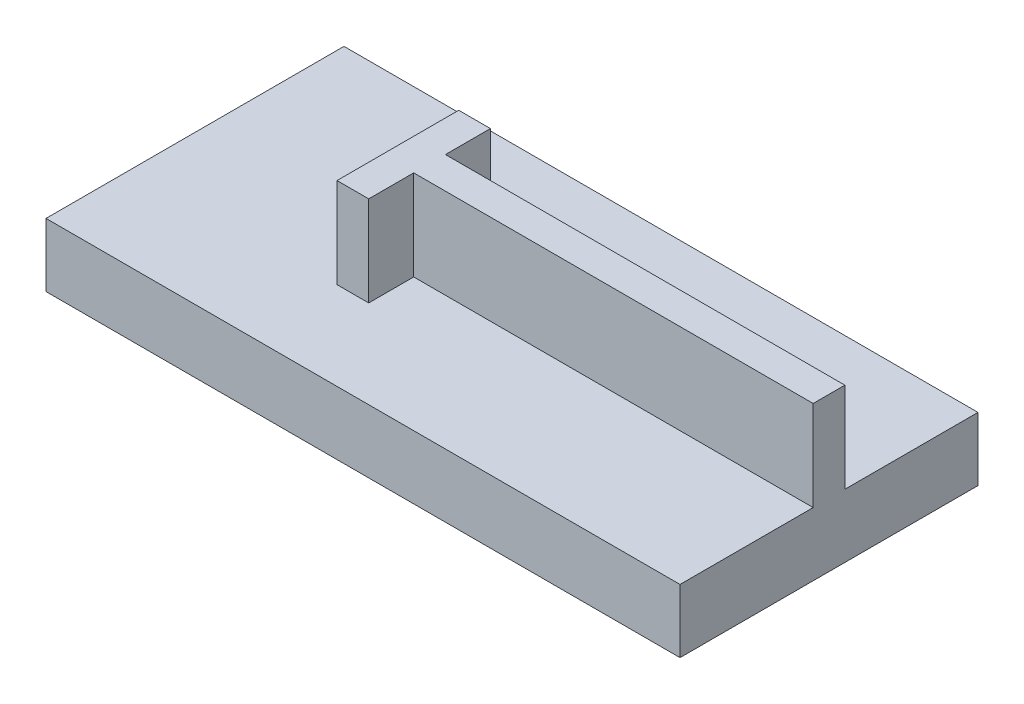
from build123d import *

# Parameters (mm, degrees)
ESQUISSE1_W        = 100
ESQUISSE1_H        = 47
BOSS_EXTRU_1_DEPTH = 10
BOSS_EXTRU_3_DEPTH = 14.22


with BuildPart() as part:
    # Esquisse1 → Boss.-Extru.1 (new body)
    with BuildSketch(Plane(origin=(0, 0, 0), x_dir=(1, 0, 0), z_dir=(0, 1, 0))):
        Rectangle(ESQUISSE1_W, ESQUISSE1_H)
    extrude(amount=BOSS_EXTRU_1_DEPTH)

    # Esquisse2 → Boss.-Extru.3 (add)
    with BuildSketch(Plane(origin=(0, 10, 0), x_dir=(1, 0, 0), z_dir=(0, 1, 0))):
        Polygon((50, -2.5), (50, 2.5), (-13, 2.5), (-13, 9.6), (-18, 9.6), (-18, -9.6), (-13, -9.6), (-13, -2.5), align=None)
    extrude(amount=BOSS_EXTRU_3_DEPTH)


solid = part.part
